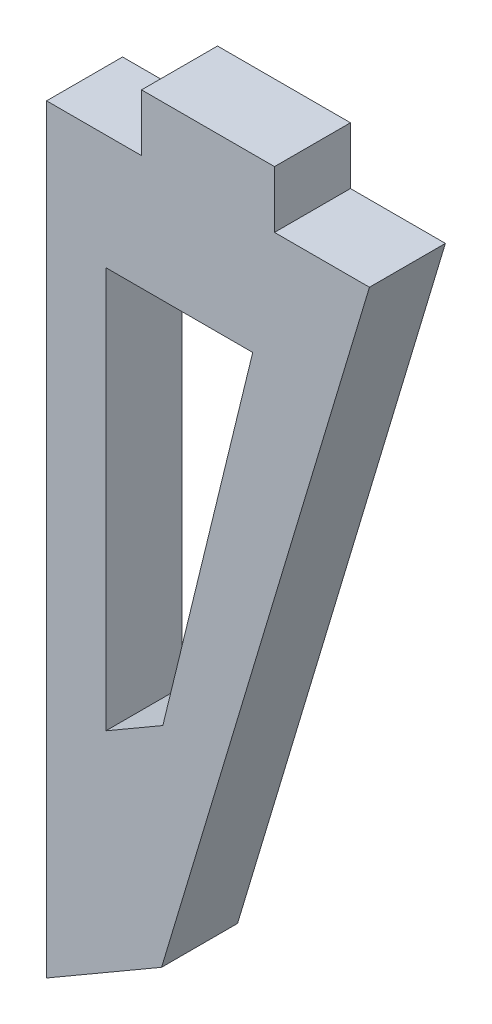
from build123d import *

# Parameters (mm, degrees)
BOSS_EXTRUDE1_DEPTH = 2


with BuildPart() as part:
    # Sketch1 → Boss-Extrude1 (new body)
    with BuildSketch(Plane.XY):
        Polygon((-8.5, 0), (-8.5, -20), (-5.47292158, -18.243071932), (0, 0), (-2.5, 0), (-2.5, 1.5), (-6, 1.5), (-6, 0), align=None)
        Polygon((-3.439362664, -4.523577139), (-5.439362664, -12.713119984), (-6.939362664, -13.583725808), (-6.939362664, -12.713119984), (-6.939362664, -11.713119984), (-6.939362664, -4.523577139), (-6.939362664, -3.023577139), (-3.439362664, -3.023577139), (-3.07304185, -3.023577139), align=None, mode=Mode.SUBTRACT)
    extrude(amount=BOSS_EXTRUDE1_DEPTH)


solid = part.part
